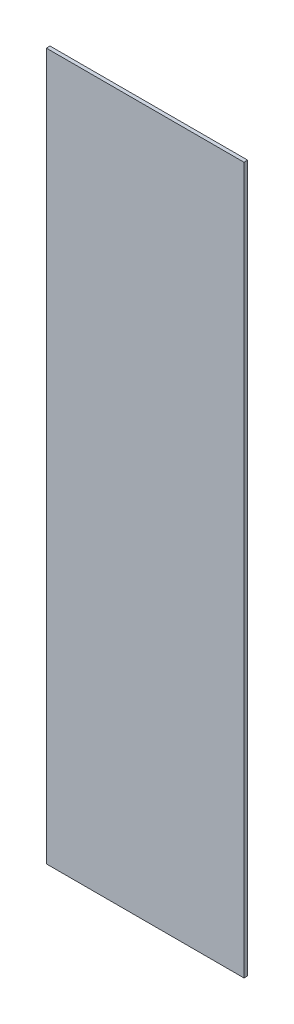
from build123d import *

# Parameters (mm, degrees)
SKETCH1_W           = 171.45
SKETCH1_H           = 3.175
BOSS_EXTRUDE1_DEPTH = 306.3875


with BuildPart() as part:
    # Sketch1 → Boss-Extrude1 (new body, symmetric)
    with BuildSketch(Plane(origin=(0, 0, 0), x_dir=(1, 0, 0), z_dir=(0, 1, 0))):
        with Locations((85.725, 1.5875)):
            Rectangle(SKETCH1_W, SKETCH1_H)
    extrude(amount=BOSS_EXTRUDE1_DEPTH, both=True)


solid = part.part
